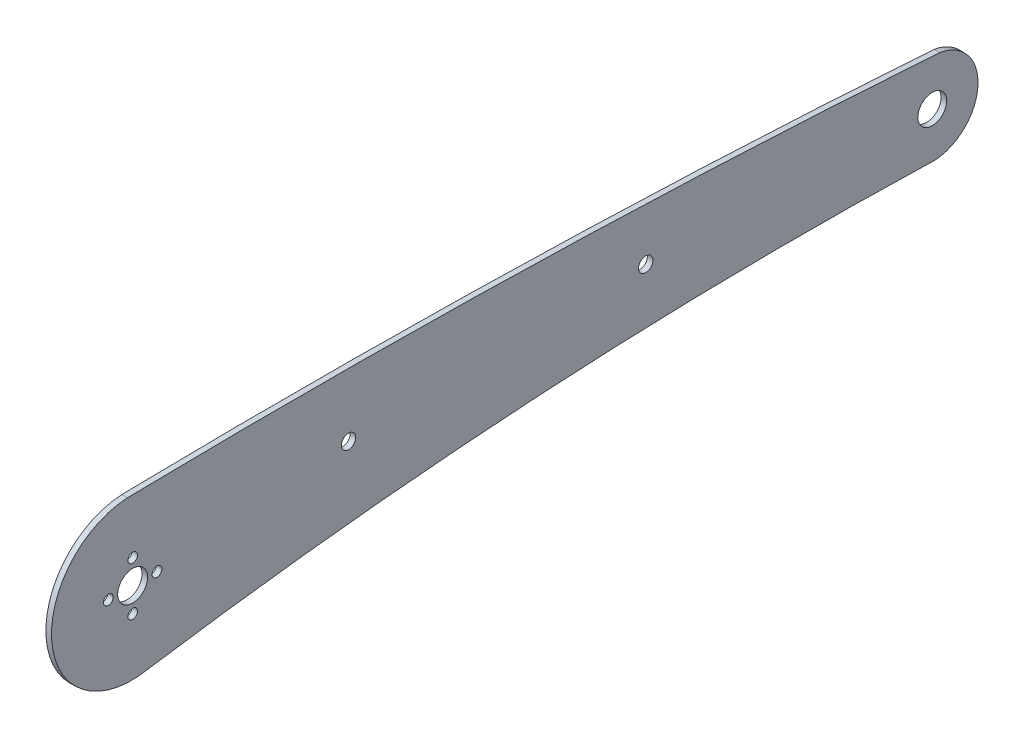
from build123d import *

# Parameters (mm, degrees)
SKETCH_1_R      = 1.3
SKETCH_1_R_2    = 4
SKETCH_1_R_3    = 1.925
SKETCH_1_R_4    = 3.85
EXTRUDE_1_DEPTH = 1.5


with BuildPart() as part:
    # 草圖1 → 填料-伸長1 (new body)
    with BuildSketch(Plane(origin=(0, 0, 0), x_dir=(0, 0, -1), z_dir=(1, 0, 0))):
        with BuildLine():
            ThreePointArc((111.555989952, -8.572011863), (6.374730125, -10.137132711), (-98.230068302, -21.244930328))
            ThreePointArc((-98.230068302, -21.244930328), (-123.67575498, -2.873316644), (-103.541794939, 21.20204032))
            ThreePointArc((-103.541794939, 21.20204032), (5.082777822, 20.871677912), (113.584507189, 15.696576829))
            ThreePointArc((113.584507189, 15.696576829), (123.827345593, 3.028727453), (112.406990492, -8.588743688))
            ThreePointArc((112.406990492, -8.588743688), (111.981133536, -8.59851924), (111.555989952, -8.572011863))
        make_face()
        with Locations((-102.143981395, 6.633331517)):
            Circle(SKETCH_1_R, mode=Mode.SUBTRACT)
        with Locations((-108.643981395, 0.133331517)):
            Circle(SKETCH_1_R, mode=Mode.SUBTRACT)
        with Locations((-102.143981395, -6.366668483)):
            Circle(SKETCH_1_R, mode=Mode.SUBTRACT)
        with Locations((-95.643981395, 0.133331517)):
            Circle(SKETCH_1_R, mode=Mode.SUBTRACT)
        with Locations((-102.143981395, 0.133331517)):
            Circle(SKETCH_1_R_2, mode=Mode.SUBTRACT)
        with Locations((35.001055541, 5.982881827)):
            Circle(SKETCH_1_R_3, mode=Mode.SUBTRACT)
        with Locations((-44.432813653, 4.686665047)):
            Circle(SKETCH_1_R_3, mode=Mode.SUBTRACT)
        with Locations((111.605339346, 3.621333032)):
            Circle(SKETCH_1_R_4, mode=Mode.SUBTRACT)
    extrude(amount=EXTRUDE_1_DEPTH)


solid = part.part
